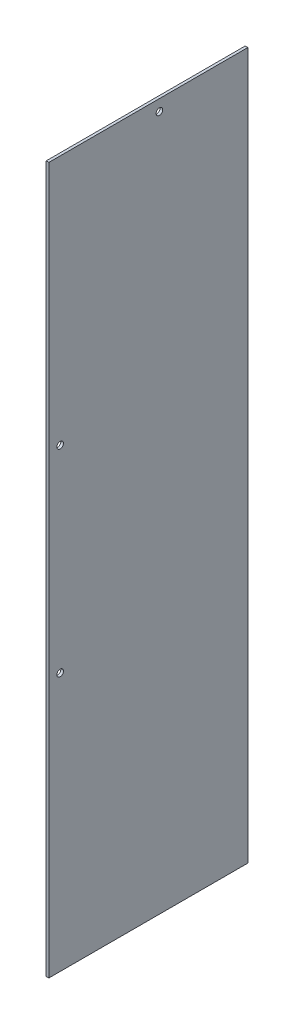
from build123d import *

# Parameters (mm, degrees)
SKETCH1_W           = 228.981
SKETCH1_H           = 813.181
BOSS_EXTRUDE1_DEPTH = 3.0734
CUT_EXTRUDE1_REACH  = 5.073
SKETCH2_R           = 3.81


with BuildPart() as part:
    # Sketch1 → Boss-Extrude1 (new body)
    with BuildSketch(Plane(origin=(0, 0, 0), x_dir=(0, 0, -1), z_dir=(1, 0, 0))):
        Rectangle(SKETCH1_W, SKETCH1_H)
    extrude(amount=BOSS_EXTRUDE1_DEPTH)

    # Sketch2 → Cut-Extrude1 (cut, up to next)
    with BuildSketch(Plane(origin=(3.0734, 0, 0), x_dir=(0, 0, -1), z_dir=(1, 0, 0)), mode=Mode.PRIVATE) as cut_extrude1_sk1:
        with Locations((12.7889, 393.6111)):
            Circle(SKETCH2_R)
    cut_extrude1_tool1 = extrude(cut_extrude1_sk1.sketch, amount=-CUT_EXTRUDE1_REACH, mode=Mode.PRIVATE) & part.part
    add(cut_extrude1_tool1.solids().sort_by_distance((3.0734, 393.6111, -12.7889))[0], mode=Mode.SUBTRACT)
    # Sketch2 → Cut-Extrude1 (cut, up to next)
    with BuildSketch(Plane(origin=(3.0734, 0, 0), x_dir=(0, 0, -1), z_dir=(1, 0, 0)), mode=Mode.PRIVATE) as cut_extrude1_sk2:
        with Locations((-101.5111, 118.165033333)):
            Circle(SKETCH2_R)
    cut_extrude1_tool2 = extrude(cut_extrude1_sk2.sketch, amount=-CUT_EXTRUDE1_REACH, mode=Mode.PRIVATE) & part.part
    add(cut_extrude1_tool2.solids().sort_by_distance((3.0734, 118.165033, 101.5111))[0], mode=Mode.SUBTRACT)
    # Sketch2 → Cut-Extrude1 (cut, up to next)
    with BuildSketch(Plane(origin=(3.0734, 0, 0), x_dir=(0, 0, -1), z_dir=(1, 0, 0)), mode=Mode.PRIVATE) as cut_extrude1_sk3:
        with Locations((-101.5111, -108.919433333)):
            Circle(SKETCH2_R)
    cut_extrude1_tool3 = extrude(cut_extrude1_sk3.sketch, amount=-CUT_EXTRUDE1_REACH, mode=Mode.PRIVATE) & part.part
    add(cut_extrude1_tool3.solids().sort_by_distance((3.0734, -108.919433, 101.5111))[0], mode=Mode.SUBTRACT)


solid = part.part
